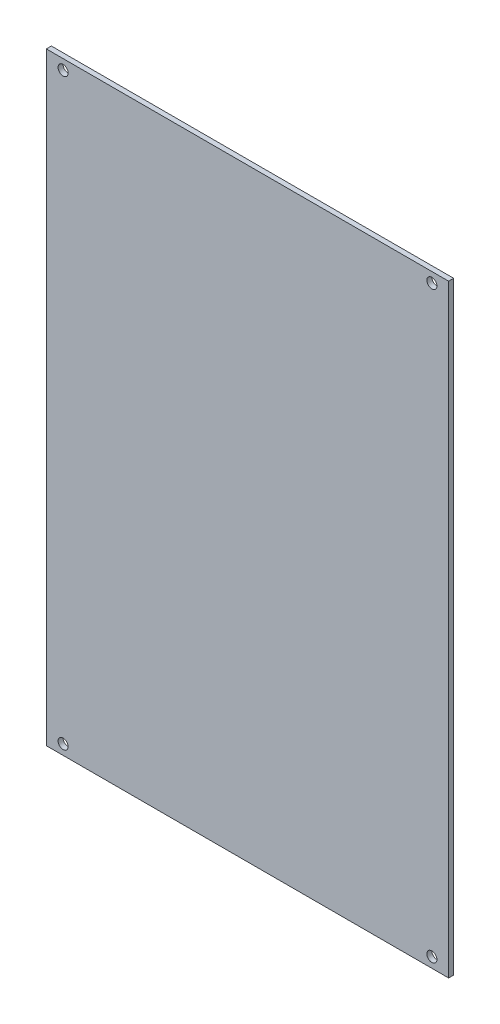
from build123d import *

# Parameters (mm, degrees)
SKETCH_1_W      = 1200
SKETCH_1_H      = 1800
SKETCH_1_R      = 15
EXTRUDE_1_DEPTH = 3
SCALE_1_SCALE_X = 0.1
SCALE_1_SCALE_Y = 0.1
SCALE_1_SCALE_Z = 0.5


with BuildPart() as part:
    # 草图1 → 凸台-拉伸1 (new body)
    with BuildSketch(Plane.XY):
        with Locations((4161.569311854, 9.612957927)):
            Rectangle(SKETCH_1_W, SKETCH_1_H)
        with Locations((3611.569311854, 879.612957927)):
            Circle(SKETCH_1_R, mode=Mode.SUBTRACT)
        with Locations((4711.569311854, 879.612957927)):
            Circle(SKETCH_1_R, mode=Mode.SUBTRACT)
        with Locations((3611.569311854, -860.387042073)):
            Circle(SKETCH_1_R, mode=Mode.SUBTRACT)
        with Locations((4711.569311854, -860.387042073)):
            Circle(SKETCH_1_R, mode=Mode.SUBTRACT)
    extrude(amount=EXTRUDE_1_DEPTH)


with BuildPart() as part_1:
    # 缩放比例1: scaled about (4161.569311854, 9.612957927, 1.5)
    add(part.part.scale((SCALE_1_SCALE_X, SCALE_1_SCALE_Y, SCALE_1_SCALE_Z), about=(4161.569311854, 9.612957927, 1.5)))


solid = part_1.part
